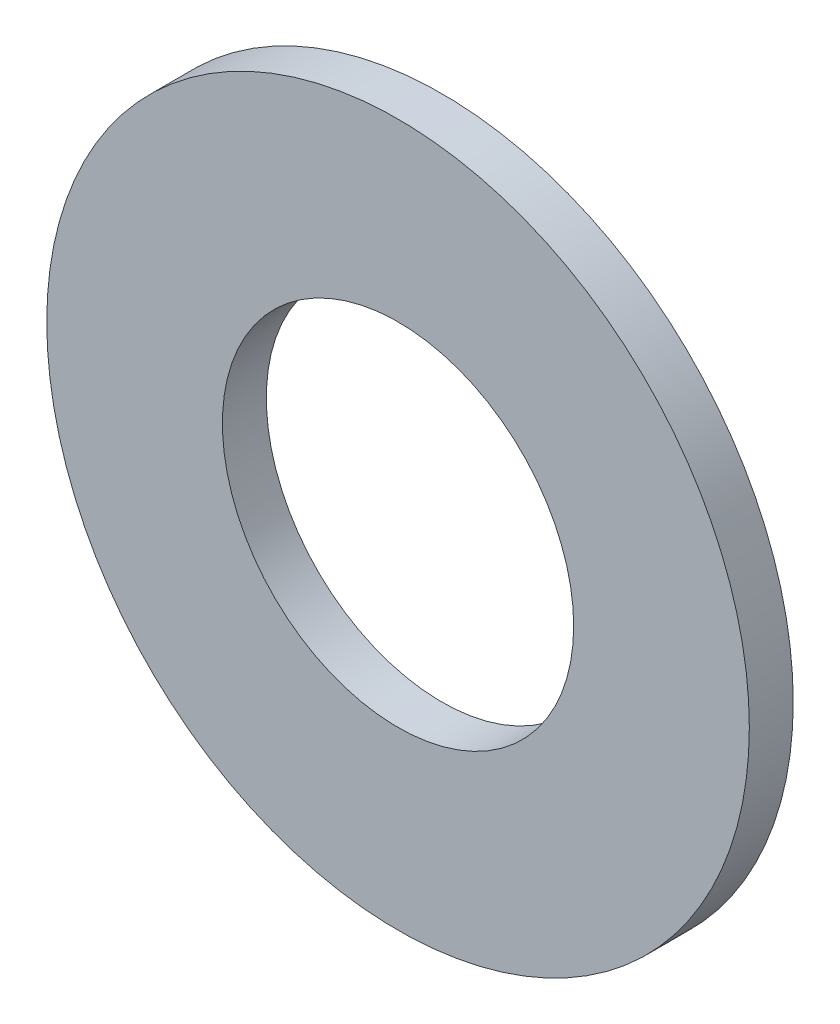
from build123d import *

# Parameters (mm, degrees)
SZKIC1_R                    = 12
SZKIC1_R_2                  = 6
DODANIE_WYCI_GNI_CIE1_DEPTH = 1.5


with BuildPart() as part:
    # Szkic1 → Dodanie-wyciągnięcie1 (new body)
    with BuildSketch(Plane.XY):
        Circle(SZKIC1_R)
        Circle(SZKIC1_R_2, mode=Mode.SUBTRACT)
    extrude(amount=DODANIE_WYCI_GNI_CIE1_DEPTH)


solid = part.part
